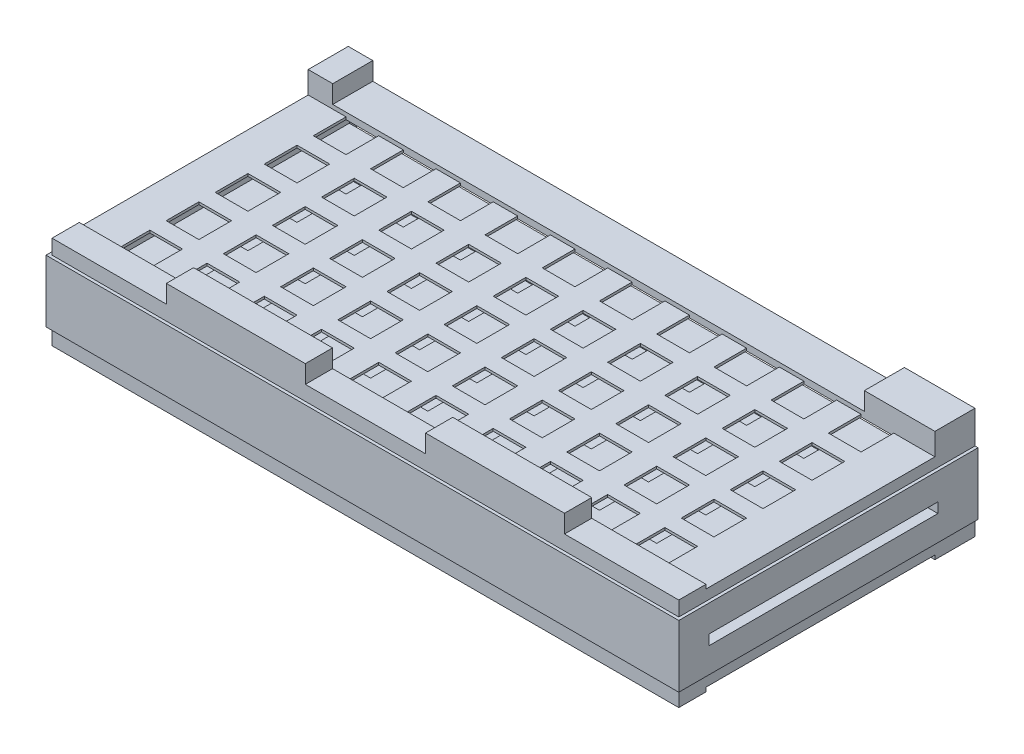
from build123d import *

# Parameters (mm, degrees)
SZKIC1_W                     = 374
SZKIC1_H                     = 53
DODANIE_WYCI_GNI_CIE1_DEPTH  = 177
SZKIC5_W                     = 20
SZKIC5_H                     = 20
WYTNIJ_WYCI_GNI_CIE4_DEPTH   = 104
SZKIC7_W                     = 370
SZKIC7_H                     = 19.4
WYTNIJ_WYCI_GNI_CIE5_DEPTH   = 175
SZKIC9_W                     = 140
SZKIC9_H                     = 6.2
WYTNIJ_WYCI_GNI_CIE6_DEPTH   = 374
SZKIC15_W                    = 374
SZKIC15_H                    = 177
SZKIC15_W_2                  = 20
SZKIC15_H_2                  = 20
DODANIE_WYCI_GNI_CIE6_DEPTH  = 1
SZKIC16_W                    = 374
SZKIC16_H                    = 177
SZKIC16_W_2                  = 20
SZKIC16_H_2                  = 20
DODANIE_WYCI_GNI_CIE7_DEPTH  = 1
SZKIC17_W                    = 177
SZKIC17_H                    = 55
SZKIC17_W_2                  = 140
SZKIC17_H_2                  = 6.2
DODANIE_WYCI_GNI_CIE8_DEPTH  = 1
SZKIC18_W                    = 177
SZKIC18_H                    = 55
SZKIC18_W_2                  = 140
SZKIC18_H_2                  = 6.2
DODANIE_WYCI_GNI_CIE9_DEPTH  = 1
SZKIC19_W                    = 376
SZKIC19_H                    = 55
SZKIC19_W_2                  = 373
SZKIC19_H_2                  = 52
DODANIE_WYCI_GNI_CIE10_DEPTH = 6
SZKIC21_W                    = 376
SZKIC21_H                    = 140
WYTNIJ_WYCI_GNI_CIE7_DEPTH   = 1.5
SZKIC22_W                    = 376
SZKIC22_H                    = 140
WYTNIJ_WYCI_GNI_CIE8_DEPTH   = 1.5
SZKIC23_W                    = 140
SZKIC23_H                    = 6.2
DODANIE_WYCI_GNI_CIE11_DEPTH = 5.5
SZKIC24_W                    = 140
SZKIC24_H                    = 6.2
DODANIE_WYCI_GNI_CIE12_DEPTH = 5.5
SZKIC25_W                    = 387
SZKIC25_H                    = 24.5
SZKIC25_H_2                  = 18.5
DODANIE_WYCI_GNI_CIE13_DEPTH = 1
SZKIC26_W                    = 387
SZKIC26_H                    = 24.5
SZKIC26_H_2                  = 18.5
DODANIE_WYCI_GNI_CIE14_DEPTH = 1
SZKIC31_W                    = 387
SZKIC31_H                    = 10
WYTNIJ_WYCI_GNI_CIE12_DEPTH  = 1.85
WYTNIJ_WYCI_GNI_CIE13_DEPTH  = 1.85
WYTNIJ_WYCI_GNI_CIE14_DEPTH  = 1.85
SZKIC34_W                    = 383.3
SZKIC34_H                    = 9
WYTNIJ_WYCI_GNI_CIE15_DEPTH  = 1.85
SZKIC35_W                    = 85
SZKIC35_H                    = 16.65
DODANIE_WYCI_GNI_CIE15_DEPTH = 11
SZKIC36_W                    = 43.15
SZKIC36_H                    = 24.5
SZKIC36_W_2                  = 15
DODANIE_WYCI_GNI_CIE16_DEPTH = 11


with BuildPart() as part:
    # Szkic1 → Dodanie-wyciągnięcie1 (new body)
    with BuildSketch(Plane.XY):
        with Locations((-1, 7.6)):
            Rectangle(SZKIC1_W, SZKIC1_H)
    extrude(amount=DODANIE_WYCI_GNI_CIE1_DEPTH)

    # Szkic5 → Wytnij-wyciągnięcie4 (cut)
    with BuildSketch(Plane.XZ.offset(18.9)):
        with Locations((155.5, 58.5)):
            Rectangle(SZKIC5_W, SZKIC5_H)
        with Locations((155.5, 28.5)):
            Rectangle(SZKIC5_W, SZKIC5_H)
        with Locations((155.5, 88.5)):
            Rectangle(SZKIC5_W, SZKIC5_H)
        with Locations((155.5, 118.5)):
            Rectangle(SZKIC5_W, SZKIC5_H)
        with Locations((155.5, 148.5)):
            Rectangle(SZKIC5_W, SZKIC5_H)
        with Locations((120.5, 58.5)):
            Rectangle(SZKIC5_W, SZKIC5_H)
        with Locations((120.5, 28.5)):
            Rectangle(SZKIC5_W, SZKIC5_H)
        with Locations((120.5, 88.5)):
            Rectangle(SZKIC5_W, SZKIC5_H)
        with Locations((120.5, 118.5)):
            Rectangle(SZKIC5_W, SZKIC5_H)
        with Locations((120.5, 148.5)):
            Rectangle(SZKIC5_W, SZKIC5_H)
        with Locations((85.5, 58.5)):
            Rectangle(SZKIC5_W, SZKIC5_H)
        with Locations((85.5, 28.5)):
            Rectangle(SZKIC5_W, SZKIC5_H)
        with Locations((85.5, 88.5)):
            Rectangle(SZKIC5_W, SZKIC5_H)
        with Locations((85.5, 118.5)):
            Rectangle(SZKIC5_W, SZKIC5_H)
        with Locations((85.5, 148.5)):
            Rectangle(SZKIC5_W, SZKIC5_H)
        with Locations((50.5, 58.5)):
            Rectangle(SZKIC5_W, SZKIC5_H)
        with Locations((50.5, 28.5)):
            Rectangle(SZKIC5_W, SZKIC5_H)
        with Locations((50.5, 88.5)):
            Rectangle(SZKIC5_W, SZKIC5_H)
        with Locations((50.5, 118.5)):
            Rectangle(SZKIC5_W, SZKIC5_H)
        with Locations((50.5, 148.5)):
            Rectangle(SZKIC5_W, SZKIC5_H)
        with Locations((15.5, 58.5)):
            Rectangle(SZKIC5_W, SZKIC5_H)
        with Locations((15.5, 28.5)):
            Rectangle(SZKIC5_W, SZKIC5_H)
        with Locations((15.5, 88.5)):
            Rectangle(SZKIC5_W, SZKIC5_H)
        with Locations((15.5, 118.5)):
            Rectangle(SZKIC5_W, SZKIC5_H)
        with Locations((15.5, 148.5)):
            Rectangle(SZKIC5_W, SZKIC5_H)
        with Locations((-19.5, 58.5)):
            Rectangle(SZKIC5_W, SZKIC5_H)
        with Locations((-19.5, 28.5)):
            Rectangle(SZKIC5_W, SZKIC5_H)
        with Locations((-19.5, 88.5)):
            Rectangle(SZKIC5_W, SZKIC5_H)
        with Locations((-19.5, 118.5)):
            Rectangle(SZKIC5_W, SZKIC5_H)
        with Locations((-19.5, 148.5)):
            Rectangle(SZKIC5_W, SZKIC5_H)
        with Locations((-54.5, 58.5)):
            Rectangle(SZKIC5_W, SZKIC5_H)
        with Locations((-54.5, 28.5)):
            Rectangle(SZKIC5_W, SZKIC5_H)
        with Locations((-54.5, 88.5)):
            Rectangle(SZKIC5_W, SZKIC5_H)
        with Locations((-54.5, 118.5)):
            Rectangle(SZKIC5_W, SZKIC5_H)
        with Locations((-54.5, 148.5)):
            Rectangle(SZKIC5_W, SZKIC5_H)
        with Locations((-89.5, 58.5)):
            Rectangle(SZKIC5_W, SZKIC5_H)
        with Locations((-89.5, 28.5)):
            Rectangle(SZKIC5_W, SZKIC5_H)
        with Locations((-89.5, 88.5)):
            Rectangle(SZKIC5_W, SZKIC5_H)
        with Locations((-89.5, 118.5)):
            Rectangle(SZKIC5_W, SZKIC5_H)
        with Locations((-89.5, 148.5)):
            Rectangle(SZKIC5_W, SZKIC5_H)
        with Locations((-124.5, 58.5)):
            Rectangle(SZKIC5_W, SZKIC5_H)
        with Locations((-124.5, 28.5)):
            Rectangle(SZKIC5_W, SZKIC5_H)
        with Locations((-124.5, 88.5)):
            Rectangle(SZKIC5_W, SZKIC5_H)
        with Locations((-124.5, 118.5)):
            Rectangle(SZKIC5_W, SZKIC5_H)
        with Locations((-124.5, 148.5)):
            Rectangle(SZKIC5_W, SZKIC5_H)
        with Locations((-159.5, 58.5)):
            Rectangle(SZKIC5_W, SZKIC5_H)
        with Locations((-159.5, 28.5)):
            Rectangle(SZKIC5_W, SZKIC5_H)
        with Locations((-159.5, 88.5)):
            Rectangle(SZKIC5_W, SZKIC5_H)
        with Locations((-159.5, 118.5)):
            Rectangle(SZKIC5_W, SZKIC5_H)
        with Locations((-159.5, 148.5)):
            Rectangle(SZKIC5_W, SZKIC5_H)
    extrude(amount=-WYTNIJ_WYCI_GNI_CIE4_DEPTH, mode=Mode.SUBTRACT)

    # Szkic7 → Wytnij-wyciągnięcie5 (cut)
    with BuildSketch(Plane(origin=(0, 0, 0), x_dir=(-1, 0, 0), z_dir=(0, 0, -1))):
        with Locations((1, 22.4)):
            Rectangle(SZKIC7_W, SZKIC7_H)
        with Locations((1, -7.2)):
            Rectangle(SZKIC7_W, SZKIC7_H)
    extrude(amount=-WYTNIJ_WYCI_GNI_CIE5_DEPTH, mode=Mode.SUBTRACT)

    # Szkic9 → Wytnij-wyciągnięcie6 (cut)
    with BuildSketch(Plane(origin=(186, 0, 0), x_dir=(0, 0, -1), z_dir=(1, 0, 0))):
        with Locations((-88.5, 7.6)):
            Rectangle(SZKIC9_W, SZKIC9_H)
    extrude(amount=-WYTNIJ_WYCI_GNI_CIE6_DEPTH, mode=Mode.SUBTRACT)

    # Szkic15 → Dodanie-wyciągnięcie6 (add)
    with BuildSketch(Plane(origin=(0, 34.1, 0), x_dir=(1, 0, 0), z_dir=(0, 1, 0))):
        with Locations((-1, -88.5)):
            Rectangle(SZKIC15_W, SZKIC15_H)
        with Locations((-159.5, -28.5)):
            Rectangle(SZKIC15_W_2, SZKIC15_H_2, mode=Mode.SUBTRACT)
        with Locations((-124.5, -28.5)):
            Rectangle(SZKIC15_W_2, SZKIC15_H_2, mode=Mode.SUBTRACT)
        with Locations((-89.5, -28.5)):
            Rectangle(SZKIC15_W_2, SZKIC15_H_2, mode=Mode.SUBTRACT)
        with Locations((-54.5, -28.5)):
            Rectangle(SZKIC15_W_2, SZKIC15_H_2, mode=Mode.SUBTRACT)
        with Locations((-19.5, -28.5)):
            Rectangle(SZKIC15_W_2, SZKIC15_H_2, mode=Mode.SUBTRACT)
        with Locations((15.5, -28.5)):
            Rectangle(SZKIC15_W_2, SZKIC15_H_2, mode=Mode.SUBTRACT)
        with Locations((50.5, -28.5)):
            Rectangle(SZKIC15_W_2, SZKIC15_H_2, mode=Mode.SUBTRACT)
        with Locations((85.5, -28.5)):
            Rectangle(SZKIC15_W_2, SZKIC15_H_2, mode=Mode.SUBTRACT)
        with Locations((120.5, -28.5)):
            Rectangle(SZKIC15_W_2, SZKIC15_H_2, mode=Mode.SUBTRACT)
        with Locations((155.5, -28.5)):
            Rectangle(SZKIC15_W_2, SZKIC15_H_2, mode=Mode.SUBTRACT)
        with Locations((155.5, -58.5)):
            Rectangle(SZKIC15_W_2, SZKIC15_H_2, mode=Mode.SUBTRACT)
        with Locations((155.5, -88.5)):
            Rectangle(SZKIC15_W_2, SZKIC15_H_2, mode=Mode.SUBTRACT)
        with Locations((155.5, -118.5)):
            Rectangle(SZKIC15_W_2, SZKIC15_H_2, mode=Mode.SUBTRACT)
        with Locations((155.5, -148.5)):
            Rectangle(SZKIC15_W_2, SZKIC15_H_2, mode=Mode.SUBTRACT)
        with Locations((120.5, -58.5)):
            Rectangle(SZKIC15_W_2, SZKIC15_H_2, mode=Mode.SUBTRACT)
        with Locations((120.5, -88.5)):
            Rectangle(SZKIC15_W_2, SZKIC15_H_2, mode=Mode.SUBTRACT)
        with Locations((120.5, -118.5)):
            Rectangle(SZKIC15_W_2, SZKIC15_H_2, mode=Mode.SUBTRACT)
        with Locations((120.5, -148.5)):
            Rectangle(SZKIC15_W_2, SZKIC15_H_2, mode=Mode.SUBTRACT)
        with Locations((85.5, -58.5)):
            Rectangle(SZKIC15_W_2, SZKIC15_H_2, mode=Mode.SUBTRACT)
        with Locations((85.5, -88.5)):
            Rectangle(SZKIC15_W_2, SZKIC15_H_2, mode=Mode.SUBTRACT)
        with Locations((85.5, -118.5)):
            Rectangle(SZKIC15_W_2, SZKIC15_H_2, mode=Mode.SUBTRACT)
        with Locations((85.5, -148.5)):
            Rectangle(SZKIC15_W_2, SZKIC15_H_2, mode=Mode.SUBTRACT)
        with Locations((50.5, -58.5)):
            Rectangle(SZKIC15_W_2, SZKIC15_H_2, mode=Mode.SUBTRACT)
        with Locations((50.5, -88.5)):
            Rectangle(SZKIC15_W_2, SZKIC15_H_2, mode=Mode.SUBTRACT)
        with Locations((50.5, -118.5)):
            Rectangle(SZKIC15_W_2, SZKIC15_H_2, mode=Mode.SUBTRACT)
        with Locations((15.5, -58.5)):
            Rectangle(SZKIC15_W_2, SZKIC15_H_2, mode=Mode.SUBTRACT)
        with Locations((15.5, -88.5)):
            Rectangle(SZKIC15_W_2, SZKIC15_H_2, mode=Mode.SUBTRACT)
        with Locations((15.5, -118.5)):
            Rectangle(SZKIC15_W_2, SZKIC15_H_2, mode=Mode.SUBTRACT)
        with Locations((15.5, -148.5)):
            Rectangle(SZKIC15_W_2, SZKIC15_H_2, mode=Mode.SUBTRACT)
        with Locations((50.5, -148.5)):
            Rectangle(SZKIC15_W_2, SZKIC15_H_2, mode=Mode.SUBTRACT)
        with Locations((-19.5, -58.5)):
            Rectangle(SZKIC15_W_2, SZKIC15_H_2, mode=Mode.SUBTRACT)
        with Locations((-19.5, -88.5)):
            Rectangle(SZKIC15_W_2, SZKIC15_H_2, mode=Mode.SUBTRACT)
        with Locations((-19.5, -118.5)):
            Rectangle(SZKIC15_W_2, SZKIC15_H_2, mode=Mode.SUBTRACT)
        with Locations((-19.5, -148.5)):
            Rectangle(SZKIC15_W_2, SZKIC15_H_2, mode=Mode.SUBTRACT)
        with Locations((-54.5, -58.5)):
            Rectangle(SZKIC15_W_2, SZKIC15_H_2, mode=Mode.SUBTRACT)
        with Locations((-54.5, -88.5)):
            Rectangle(SZKIC15_W_2, SZKIC15_H_2, mode=Mode.SUBTRACT)
        with Locations((-54.5, -118.5)):
            Rectangle(SZKIC15_W_2, SZKIC15_H_2, mode=Mode.SUBTRACT)
        with Locations((-54.5, -148.5)):
            Rectangle(SZKIC15_W_2, SZKIC15_H_2, mode=Mode.SUBTRACT)
        with Locations((-89.5, -58.5)):
            Rectangle(SZKIC15_W_2, SZKIC15_H_2, mode=Mode.SUBTRACT)
        with Locations((-89.5, -88.5)):
            Rectangle(SZKIC15_W_2, SZKIC15_H_2, mode=Mode.SUBTRACT)
        with Locations((-89.5, -118.5)):
            Rectangle(SZKIC15_W_2, SZKIC15_H_2, mode=Mode.SUBTRACT)
        with Locations((-89.5, -148.5)):
            Rectangle(SZKIC15_W_2, SZKIC15_H_2, mode=Mode.SUBTRACT)
        with Locations((-124.5, -58.5)):
            Rectangle(SZKIC15_W_2, SZKIC15_H_2, mode=Mode.SUBTRACT)
        with Locations((-124.5, -88.5)):
            Rectangle(SZKIC15_W_2, SZKIC15_H_2, mode=Mode.SUBTRACT)
        with Locations((-124.5, -118.5)):
            Rectangle(SZKIC15_W_2, SZKIC15_H_2, mode=Mode.SUBTRACT)
        with Locations((-124.5, -148.5)):
            Rectangle(SZKIC15_W_2, SZKIC15_H_2, mode=Mode.SUBTRACT)
        with Locations((-159.5, -58.5)):
            Rectangle(SZKIC15_W_2, SZKIC15_H_2, mode=Mode.SUBTRACT)
        with Locations((-159.5, -88.5)):
            Rectangle(SZKIC15_W_2, SZKIC15_H_2, mode=Mode.SUBTRACT)
        with Locations((-159.5, -118.5)):
            Rectangle(SZKIC15_W_2, SZKIC15_H_2, mode=Mode.SUBTRACT)
        with Locations((-159.5, -148.5)):
            Rectangle(SZKIC15_W_2, SZKIC15_H_2, mode=Mode.SUBTRACT)
    extrude(amount=DODANIE_WYCI_GNI_CIE6_DEPTH)

    # Szkic16 → Dodanie-wyciągnięcie7 (add)
    with BuildSketch(Plane.XZ.offset(18.9)):
        with Locations((-1, 88.5)):
            Rectangle(SZKIC16_W, SZKIC16_H)
        with Locations((155.5, 28.5)):
            Rectangle(SZKIC16_W_2, SZKIC16_H_2, mode=Mode.SUBTRACT)
        with Locations((120.5, 28.5)):
            Rectangle(SZKIC16_W_2, SZKIC16_H_2, mode=Mode.SUBTRACT)
        with Locations((85.5, 28.5)):
            Rectangle(SZKIC16_W_2, SZKIC16_H_2, mode=Mode.SUBTRACT)
        with Locations((50.5, 28.5)):
            Rectangle(SZKIC16_W_2, SZKIC16_H_2, mode=Mode.SUBTRACT)
        with Locations((15.5, 28.5)):
            Rectangle(SZKIC16_W_2, SZKIC16_H_2, mode=Mode.SUBTRACT)
        with Locations((-19.5, 28.5)):
            Rectangle(SZKIC16_W_2, SZKIC16_H_2, mode=Mode.SUBTRACT)
        with Locations((-54.5, 28.5)):
            Rectangle(SZKIC16_W_2, SZKIC16_H_2, mode=Mode.SUBTRACT)
        with Locations((-89.5, 28.5)):
            Rectangle(SZKIC16_W_2, SZKIC16_H_2, mode=Mode.SUBTRACT)
        with Locations((-124.5, 28.5)):
            Rectangle(SZKIC16_W_2, SZKIC16_H_2, mode=Mode.SUBTRACT)
        with Locations((-159.5, 28.5)):
            Rectangle(SZKIC16_W_2, SZKIC16_H_2, mode=Mode.SUBTRACT)
        with Locations((155.5, 58.5)):
            Rectangle(SZKIC16_W_2, SZKIC16_H_2, mode=Mode.SUBTRACT)
        with Locations((120.5, 58.5)):
            Rectangle(SZKIC16_W_2, SZKIC16_H_2, mode=Mode.SUBTRACT)
        with Locations((85.5, 58.5)):
            Rectangle(SZKIC16_W_2, SZKIC16_H_2, mode=Mode.SUBTRACT)
        with Locations((50.5, 58.5)):
            Rectangle(SZKIC16_W_2, SZKIC16_H_2, mode=Mode.SUBTRACT)
        with Locations((15.5, 58.5)):
            Rectangle(SZKIC16_W_2, SZKIC16_H_2, mode=Mode.SUBTRACT)
        with Locations((-19.5, 58.5)):
            Rectangle(SZKIC16_W_2, SZKIC16_H_2, mode=Mode.SUBTRACT)
        with Locations((-54.5, 58.5)):
            Rectangle(SZKIC16_W_2, SZKIC16_H_2, mode=Mode.SUBTRACT)
        with Locations((-89.5, 58.5)):
            Rectangle(SZKIC16_W_2, SZKIC16_H_2, mode=Mode.SUBTRACT)
        with Locations((-124.5, 58.5)):
            Rectangle(SZKIC16_W_2, SZKIC16_H_2, mode=Mode.SUBTRACT)
        with Locations((-159.5, 58.5)):
            Rectangle(SZKIC16_W_2, SZKIC16_H_2, mode=Mode.SUBTRACT)
        with Locations((-159.5, 88.5)):
            Rectangle(SZKIC16_W_2, SZKIC16_H_2, mode=Mode.SUBTRACT)
        with Locations((-159.5, 118.5)):
            Rectangle(SZKIC16_W_2, SZKIC16_H_2, mode=Mode.SUBTRACT)
        with Locations((-159.5, 148.5)):
            Rectangle(SZKIC16_W_2, SZKIC16_H_2, mode=Mode.SUBTRACT)
        with Locations((-124.5, 88.5)):
            Rectangle(SZKIC16_W_2, SZKIC16_H_2, mode=Mode.SUBTRACT)
        with Locations((-124.5, 118.5)):
            Rectangle(SZKIC16_W_2, SZKIC16_H_2, mode=Mode.SUBTRACT)
        with Locations((-124.5, 148.5)):
            Rectangle(SZKIC16_W_2, SZKIC16_H_2, mode=Mode.SUBTRACT)
        with Locations((-89.5, 88.5)):
            Rectangle(SZKIC16_W_2, SZKIC16_H_2, mode=Mode.SUBTRACT)
        with Locations((-89.5, 118.5)):
            Rectangle(SZKIC16_W_2, SZKIC16_H_2, mode=Mode.SUBTRACT)
        with Locations((-89.5, 148.5)):
            Rectangle(SZKIC16_W_2, SZKIC16_H_2, mode=Mode.SUBTRACT)
        with Locations((-54.5, 88.5)):
            Rectangle(SZKIC16_W_2, SZKIC16_H_2, mode=Mode.SUBTRACT)
        with Locations((-54.5, 118.5)):
            Rectangle(SZKIC16_W_2, SZKIC16_H_2, mode=Mode.SUBTRACT)
        with Locations((-54.5, 148.5)):
            Rectangle(SZKIC16_W_2, SZKIC16_H_2, mode=Mode.SUBTRACT)
        with Locations((-19.5, 88.5)):
            Rectangle(SZKIC16_W_2, SZKIC16_H_2, mode=Mode.SUBTRACT)
        with Locations((-19.5, 118.5)):
            Rectangle(SZKIC16_W_2, SZKIC16_H_2, mode=Mode.SUBTRACT)
        with Locations((-19.5, 148.5)):
            Rectangle(SZKIC16_W_2, SZKIC16_H_2, mode=Mode.SUBTRACT)
        with Locations((15.5, 88.5)):
            Rectangle(SZKIC16_W_2, SZKIC16_H_2, mode=Mode.SUBTRACT)
        with Locations((15.5, 118.5)):
            Rectangle(SZKIC16_W_2, SZKIC16_H_2, mode=Mode.SUBTRACT)
        with Locations((15.5, 148.5)):
            Rectangle(SZKIC16_W_2, SZKIC16_H_2, mode=Mode.SUBTRACT)
        with Locations((50.5, 88.5)):
            Rectangle(SZKIC16_W_2, SZKIC16_H_2, mode=Mode.SUBTRACT)
        with Locations((50.5, 118.5)):
            Rectangle(SZKIC16_W_2, SZKIC16_H_2, mode=Mode.SUBTRACT)
        with Locations((50.5, 148.5)):
            Rectangle(SZKIC16_W_2, SZKIC16_H_2, mode=Mode.SUBTRACT)
        with Locations((85.5, 88.5)):
            Rectangle(SZKIC16_W_2, SZKIC16_H_2, mode=Mode.SUBTRACT)
        with Locations((85.5, 118.5)):
            Rectangle(SZKIC16_W_2, SZKIC16_H_2, mode=Mode.SUBTRACT)
        with Locations((85.5, 148.5)):
            Rectangle(SZKIC16_W_2, SZKIC16_H_2, mode=Mode.SUBTRACT)
        with Locations((120.5, 88.5)):
            Rectangle(SZKIC16_W_2, SZKIC16_H_2, mode=Mode.SUBTRACT)
        with Locations((155.5, 88.5)):
            Rectangle(SZKIC16_W_2, SZKIC16_H_2, mode=Mode.SUBTRACT)
        with Locations((155.5, 118.5)):
            Rectangle(SZKIC16_W_2, SZKIC16_H_2, mode=Mode.SUBTRACT)
        with Locations((120.5, 118.5)):
            Rectangle(SZKIC16_W_2, SZKIC16_H_2, mode=Mode.SUBTRACT)
        with Locations((155.5, 148.5)):
            Rectangle(SZKIC16_W_2, SZKIC16_H_2, mode=Mode.SUBTRACT)
        with Locations((120.5, 148.5)):
            Rectangle(SZKIC16_W_2, SZKIC16_H_2, mode=Mode.SUBTRACT)
    extrude(amount=DODANIE_WYCI_GNI_CIE7_DEPTH)

    # Szkic17 → Dodanie-wyciągnięcie8 (add)
    with BuildSketch(Plane(origin=(186, 0, 0), x_dir=(0, 0, -1), z_dir=(1, 0, 0))):
        with Locations((-88.5, 7.6)):
            Rectangle(SZKIC17_W, SZKIC17_H)
        with Locations((-88.5, 7.6)):
            Rectangle(SZKIC17_W_2, SZKIC17_H_2, mode=Mode.SUBTRACT)
    extrude(amount=DODANIE_WYCI_GNI_CIE8_DEPTH)

    # Szkic18 → Dodanie-wyciągnięcie9 (add)
    with BuildSketch(Plane.ZY.offset(188)):
        with Locations((88.5, 7.6)):
            Rectangle(SZKIC18_W, SZKIC18_H)
        with Locations((88.5, 7.6)):
            Rectangle(SZKIC18_W_2, SZKIC18_H_2, mode=Mode.SUBTRACT)
    extrude(amount=DODANIE_WYCI_GNI_CIE9_DEPTH)

    # Szkic19 → Dodanie-wyciągnięcie10 (add)
    with BuildSketch(Plane(origin=(0, 0, 0), x_dir=(-1, 0, 0), z_dir=(0, 0, -1))):
        with Locations((1, 7.6)):
            Rectangle(SZKIC19_W, SZKIC19_H)
        with Locations((1, 7.6)):
            Rectangle(SZKIC19_W_2, SZKIC19_H_2, mode=Mode.SUBTRACT)
    extrude(amount=DODANIE_WYCI_GNI_CIE10_DEPTH)

    # Szkic21 → Wytnij-wyciągnięcie7 (cut)
    with BuildSketch(Plane(origin=(0, 35.1, 0), x_dir=(1, 0, 0), z_dir=(0, 1, 0))):
        with Locations((-1, -88.5)):
            Rectangle(SZKIC21_W, SZKIC21_H)
    extrude(amount=-WYTNIJ_WYCI_GNI_CIE7_DEPTH, mode=Mode.SUBTRACT)

    # Szkic22 → Wytnij-wyciągnięcie8 (cut)
    with BuildSketch(Plane.XZ.offset(19.9)):
        with Locations((-1, 88.5)):
            Rectangle(SZKIC22_W, SZKIC22_H)
    extrude(amount=-WYTNIJ_WYCI_GNI_CIE8_DEPTH, mode=Mode.SUBTRACT)

    # Szkic23 → Dodanie-wyciągnięcie11 (add)
    with BuildSketch(Plane(origin=(187, 0, 0), x_dir=(0, 0, -1), z_dir=(1, 0, 0))):
        Polygon((6, 35.1), (6, -19.9), (-18.5, -19.9), (-18.5, -18.4), (-158.5, -18.4), (-158.5, -19.9), (-177, -19.9), (-177, 35.1), (-158.5, 35.1), (-158.5, 33.6), (-18.5, 33.6), (-18.5, 35.1), align=None)
        with Locations((-88.5, 7.6)):
            Rectangle(SZKIC23_W, SZKIC23_H, mode=Mode.SUBTRACT)
    extrude(amount=DODANIE_WYCI_GNI_CIE11_DEPTH)

    # Szkic24 → Dodanie-wyciągnięcie12 (add)
    with BuildSketch(Plane.ZY.offset(189)):
        Polygon((-6, -19.9), (-6, 35.1), (18.5, 35.1), (18.5, 33.6), (158.5, 33.6), (158.5, 35.1), (177, 35.1), (177, -19.9), (158.5, -19.9), (158.5, -18.4), (18.5, -18.4), (18.5, -19.9), align=None)
        with Locations((88.5, 7.6)):
            Rectangle(SZKIC24_W, SZKIC24_H, mode=Mode.SUBTRACT)
    extrude(amount=DODANIE_WYCI_GNI_CIE12_DEPTH)

    # Szkic25 → Dodanie-wyciągnięcie13 (add)
    with BuildSketch(Plane.XZ.offset(19.9)):
        with Locations((-1, 6.25)):
            Rectangle(SZKIC25_W, SZKIC25_H)
        with Locations((-1, 167.75)):
            Rectangle(SZKIC25_W, SZKIC25_H_2)
    extrude(amount=DODANIE_WYCI_GNI_CIE13_DEPTH)

    # Szkic26 → Dodanie-wyciągnięcie14 (add)
    with BuildSketch(Plane(origin=(0, 35.1, 0), x_dir=(1, 0, 0), z_dir=(0, 1, 0))):
        with Locations((-1, -6.25)):
            Rectangle(SZKIC26_W, SZKIC26_H)
        with Locations((-1, -167.75)):
            Rectangle(SZKIC26_W, SZKIC26_H_2)
    extrude(amount=DODANIE_WYCI_GNI_CIE14_DEPTH)

    # Szkic31 → Wytnij-wyciągnięcie12 (cut)
    with BuildSketch(Plane.XY.offset(177)):
        with Locations((-1, -15.9)):
            Rectangle(SZKIC31_W, SZKIC31_H)
    extrude(amount=-WYTNIJ_WYCI_GNI_CIE12_DEPTH, mode=Mode.SUBTRACT)

    # Szkic32 → Wytnij-wyciągnięcie13 (cut)
    with BuildSketch(Plane(origin=(192.5, 0, 0), x_dir=(0, 0, -1), z_dir=(1, 0, 0))):
        Polygon((-175.15, -10.9), (6, -10.9), (6, -20.9), (-18.5, -20.9), (-18.5, -18.4), (-158.5, -18.4), (-158.5, -20.9), (-175.15, -20.9), align=None)
        Polygon((-177, 36.1), (-177, 27.1), (6, 27.1), (6, 36.1), (-18.5, 36.1), (-18.5, 33.6), (-158.5, 33.6), (-158.5, 36.1), align=None)
    extrude(amount=-WYTNIJ_WYCI_GNI_CIE13_DEPTH, mode=Mode.SUBTRACT)

    # Szkic33 → Wytnij-wyciągnięcie14 (cut)
    with BuildSketch(Plane.ZY.offset(194.5)):
        Polygon((175.15, -10.9), (-6, -10.9), (-6, -20.9), (18.5, -20.9), (18.5, -18.4), (158.5, -18.4), (158.5, -20.9), (175.15, -20.9), align=None)
        Polygon((-6, 36.1), (-6, 27.1), (177, 27.1), (177, 36.1), (158.5, 36.1), (158.5, 33.6), (18.5, 33.6), (18.5, 36.1), align=None)
    extrude(amount=-WYTNIJ_WYCI_GNI_CIE14_DEPTH, mode=Mode.SUBTRACT)

    # Szkic34 → Wytnij-wyciągnięcie15 (cut)
    with BuildSketch(Plane.XY.offset(177)):
        with Locations((-1, 31.6)):
            Rectangle(SZKIC34_W, SZKIC34_H)
    extrude(amount=-WYTNIJ_WYCI_GNI_CIE15_DEPTH, mode=Mode.SUBTRACT)

    # Szkic35 → Dodanie-wyciągnięcie15 (add)
    with BuildSketch(Plane(origin=(0, 36.1, 0), x_dir=(1, 0, 0), z_dir=(0, 1, 0))):
        with Locations((78.25, -166.825)):
            Rectangle(SZKIC35_W, SZKIC35_H)
        with Locations((-80.25, -166.825)):
            Rectangle(SZKIC35_W, SZKIC35_H)
    extrude(amount=DODANIE_WYCI_GNI_CIE15_DEPTH)

    # Szkic36 → Dodanie-wyciągnięcie16 (add)
    with BuildSketch(Plane(origin=(0, 36.1, 0), x_dir=(1, 0, 0), z_dir=(0, 1, 0))):
        with Locations((169.075, -6.25)):
            Rectangle(SZKIC36_W, SZKIC36_H)
        with Locations((-185.15, -6.25)):
            Rectangle(SZKIC36_W_2, SZKIC36_H)
    extrude(amount=DODANIE_WYCI_GNI_CIE16_DEPTH)


solid = part.part
